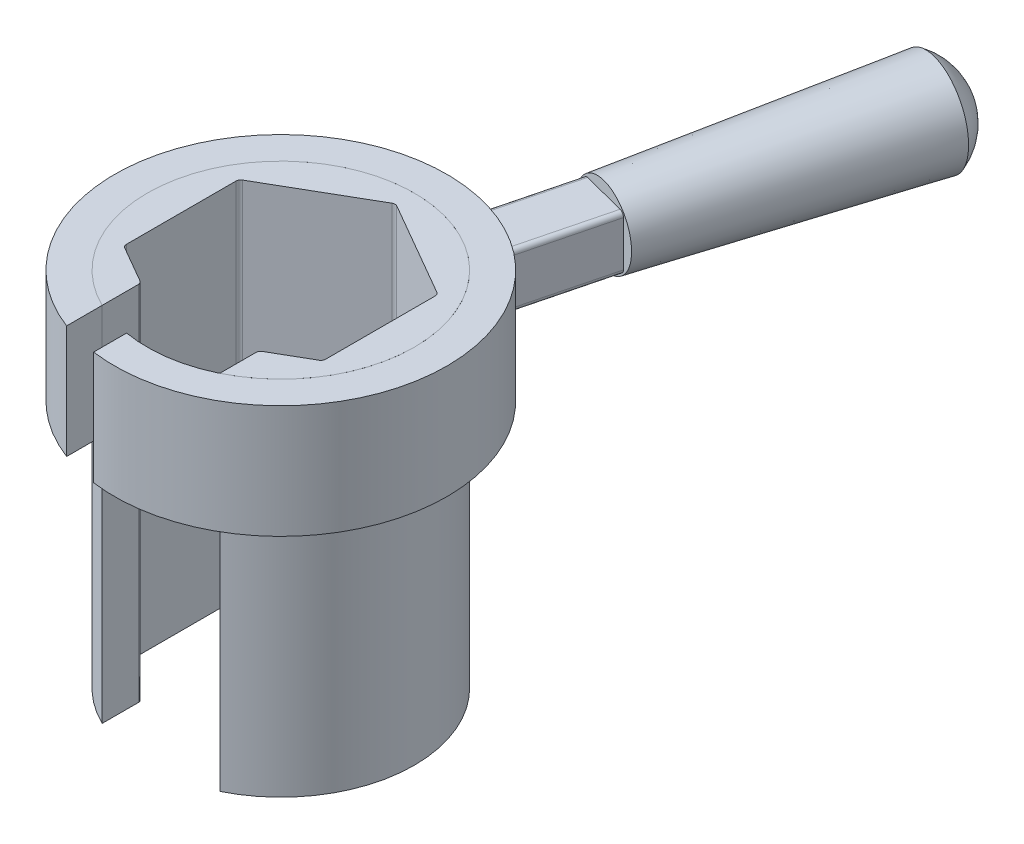
from build123d import *

# Parameters (mm, degrees)
EXTRUDE3_DEPTH                  = 40
EXTRUDE4_DEPTH                  = 12.5
SKETCH22_W                      = 6.000000000000002
SKETCH22_H                      = 6.000000000000002
EXTRUDE5_DEPTH                  = 11
EXTRUDE5_DIRECTION_2_REACH      = 60.557
EXTRUDE5_DIRECTION_2_END_RADIUS = 18.349999999999998
SKETCH23_R                      = 4.242640687119289
EXTRUDE6_DEPTH                  = 30
EXTRUDE6_DRAFT                  = -2.0000000000000044
DOME1_FACE_RADIUS               = 5.290263772
DOME1_HEIGHT                    = 3
CUT_EXTRUDE7_DEPTH              = 76.2650637528968
FILLET2_R                       = 0.5
FILLET3_R                       = 0.5


with BuildPart() as part:
    # Sketch20 → Extrude3 (new body)
    with BuildSketch(Plane(origin=(0, 0, 0), x_dir=(1, 0, 0), z_dir=(0, 1, 0))):
        with BuildLine():
            Line((-6.5, -8.874119674649425), (-6.500000000000001, -13.240562676865359))
            ThreePointArc((-6.500000000000001, -13.240562676865359), (9e-16, 14.749999999999998), (6.500000000000001, -13.240562676865359))
            Line((6.500000000000001, -13.240562676865359), (6.5, -8.874119674649425))
            ThreePointArc((6.5, -8.874119674649425), (6.7e-16, 11), (-6.5, -8.874119674649425))
        make_face()
    extrude(amount=EXTRUDE3_DEPTH)

    # Sketch24 → Cut-Extrude7 (cut, through all)
    with BuildSketch(Plane.XZ):
        Polygon((-11, 6.350852961085881), (-11, -6.350852961085884), (-1.85e-15, -12.701705922171767), (10.999999999999998, -6.350852961085879), (10.999999999999998, 6.3508529610858835), (1.7e-16, 12.701705922171767), align=None)
    extrude(amount=-CUT_EXTRUDE7_DEPTH, mode=Mode.SUBTRACT)

    # Fillet3
    fillet3_edges = [part.edges().sort_by_distance(p)[0] for p in [
        (-6.5, 20, 8.948929172439197),
        (-11, 20, 6.350852961085881),
        (6.5, 20, 8.948929172439199),
        (10.999999999999998, 20, 6.3508529610858835),
        (10.999999999999998, 20, -6.350852961085879),
        (-1.85e-15, 20, -12.701705922171767),
        (-11, 20, -6.350852961085884),
    ]]
    fillet(fillet3_edges, radius=FILLET3_R)


with BuildPart() as body_2:
    # Sketch21 → Extrude4 (new body)
    with BuildSketch(Plane(origin=(0, 39.999, 0), x_dir=(-1, 0, 0), z_dir=(0, 1, 0))):
        with BuildLine():
            Line((2.5, 14.53659176010663), (2.5, 18.17890260714326))
            ThreePointArc((2.5, 18.17890260714326), (-4.528734725810917, -17.78238065567247), (6.500000000000001, 17.160201047773302))
            Line((6.500000000000001, 17.160201047773302), (6.500000000000001, 13.240562676865359))
            ThreePointArc((6.500000000000001, 13.240562676865359), (-4.546418683552128, -14.031841545351346), (2.5, 14.53659176010663))
        make_face()
    extrude(amount=-EXTRUDE4_DEPTH)


with BuildPart() as body_3:
    # Sketch22 → Extrude5 (new body)
    with BuildSketch(Plane(origin=(4.528734725810946, 39.999, -17.78238065567246), x_dir=(-0.9690670657042212, 0, -0.246797532741741), z_dir=(0.246797532741741, 0, -0.9690670657042212))):
        with Locations((0, -6.250000000000001)):
            Rectangle(SKETCH22_W, SKETCH22_H)
    extrude(amount=EXTRUDE5_DEPTH)

    # Extrude5 direction 2: up to this cylinder (the profile starts outside it)
    extrude5_direction_2_end = Plane(origin=(0, 33.749, 0), z_dir=(0, 1, 0)) * Cylinder(EXTRUDE5_DIRECTION_2_END_RADIUS, 158.814, mode=Mode.PRIVATE)
    # Sketch22 → Extrude5 direction 2 (add, up to the surface)
    with BuildSketch(Plane(origin=(4.528734725810946, 39.999, -17.78238065567246), x_dir=(-0.9690670657042212, 0, -0.246797532741741), z_dir=(0.246797532741741, 0, -0.9690670657042212)), mode=Mode.PRIVATE) as extrude5_direction_2_sk1:
        with Locations((0, -6.250000000000001)):
            Rectangle(SKETCH22_W, SKETCH22_H)
    extrude5_direction_2_tool1 = extrude(extrude5_direction_2_sk1.sketch, amount=-EXTRUDE5_DIRECTION_2_REACH, mode=Mode.PRIVATE) - extrude5_direction_2_end
    add(extrude5_direction_2_tool1.solids().sort_by_distance((4.528735, 33.749, -17.782381))[0])
    add(extrude5_direction_2_tool1.solids().sort_by_distance((4.528735, 33.749, -17.782381))[1])


with BuildPart() as extrude6_tool:
    # Sketch23 → Extrude6 (with draft: the straight prism first)
    with BuildSketch(Plane(origin=(7.243507585970091, 0, -28.442118378418904), x_dir=(-0.9690670657042213, -1.6827536930173812e-15, -0.24679753274174074), z_dir=(0.24679753274174074, 0, -0.9690670657042213))):
        with Locations((0, 33.74899999999994)):
            Circle(SKETCH23_R)
    extrude(amount=EXTRUDE6_DEPTH)
    # Extrude6: the draft: its side faces are tilted about the plane it starts from
    extrude6_sides = [extrude6_tool.faces().sort_by_distance(p)[0] for p in [
        (15.056873939, 33.749, -41.93105111),
    ]]
    draft(extrude6_sides, Plane(origin=(7.243507585970091, 0, -28.442118378418904), x_dir=(-0.9690670657042213, -1.6827536930173812e-15, -0.24679753274174074), z_dir=(0.24679753274174074, 0, -0.9690670657042213)), EXTRUDE6_DRAFT)


with BuildPart() as body_3_1:
    add(body_3.part)

    # Extrude6: add extrude6_tool
    add(extrude6_tool.part)

    # Dome1: a dome of height H over a round flat face of radius A is a cap of a sphere of radius (A * A + H * H) / (2 * H)
    dome1_r = (DOME1_FACE_RADIUS * DOME1_FACE_RADIUS + DOME1_HEIGHT * DOME1_HEIGHT) / (2 * DOME1_HEIGHT)
    dome1_base = Plane((14.647433568, 33.749, -57.51413035), z_dir=(0.246797532742, 0, -0.969067065704))
    with Locations(dome1_base.offset(DOME1_HEIGHT - dome1_r)):
        dome1_ball = Sphere(dome1_r, mode=Mode.PRIVATE)
    add(split(dome1_ball, bisect_by=dome1_base, keep=Keep.TOP, mode=Mode.PRIVATE))

    # Fillet2
    fillet2_edges = [body_3_1.edges().sort_by_distance(p)[0] for p in [
        (8.762856119135167, 36.749, -22.252229208083023),
        (2.9484537249098373, 36.749, -23.73301440453347),
        (2.948453724909837, 30.749000000000002, -23.73301440453347),
        (8.762856119135167, 30.749000000000002, -22.252229208083023),
    ]]
    fillet(fillet2_edges, radius=FILLET2_R)


solid = Compound([part.part, body_2.part, body_3_1.part])
